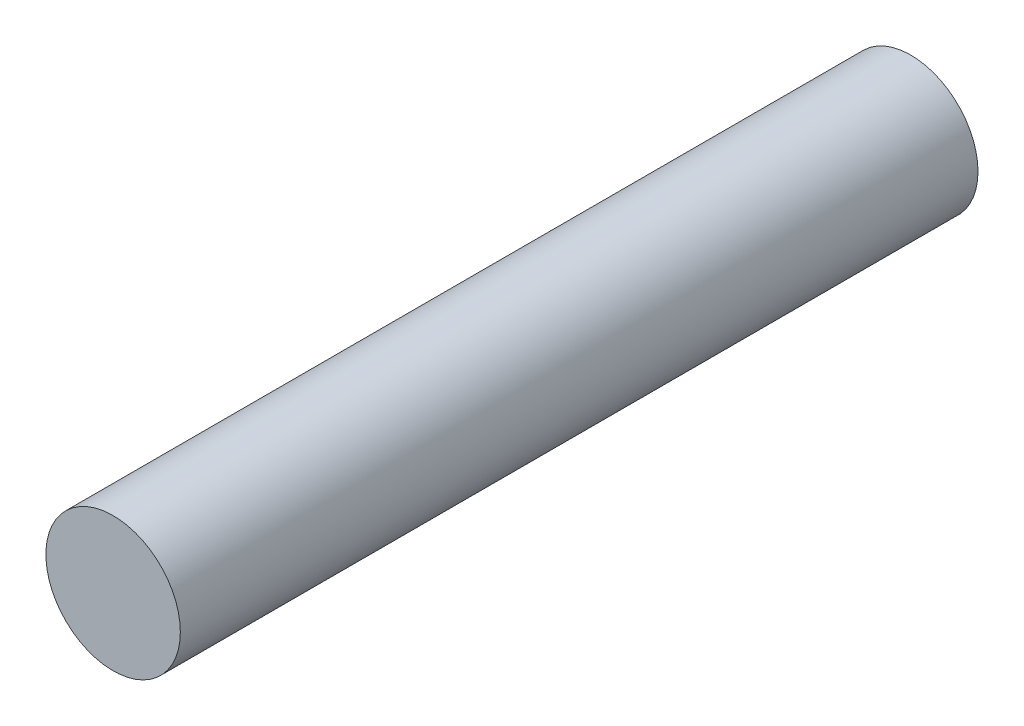
from build123d import *

# Parameters (mm, degrees)
SKETCH1_R           = 2.95
BOSS_EXTRUDE1_DEPTH = 35
CUT_EXTRUDE1_DEPTH  = 7


with BuildPart() as part:
    # Sketch1 → Boss-Extrude1 (new body)
    with BuildSketch(Plane.XY):
        Circle(SKETCH1_R)
    extrude(amount=BOSS_EXTRUDE1_DEPTH)

    # Sketch2 → Cut-Extrude1 (cut)
    with BuildSketch(Plane(origin=(0, 0, 0), x_dir=(-1, 0, 0), z_dir=(0, 0, -1))):
        with BuildLine():
            Line((-1.29614814, 1.51), (1.29614814, 1.51))
            ThreePointArc((1.29614814, 1.51), (0, -1.99), (-1.29614814, 1.51))
        make_face()
    extrude(amount=-CUT_EXTRUDE1_DEPTH, mode=Mode.SUBTRACT)


solid = part.part
